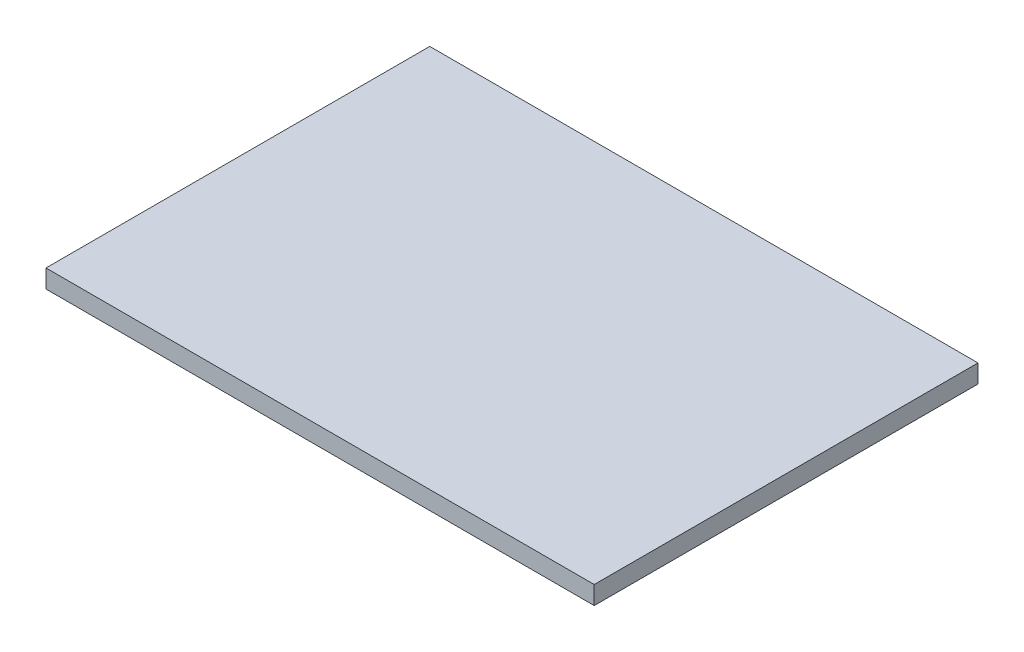
from build123d import *

# Parameters (mm, degrees)
SKETCH1_W           = 30
SKETCH1_H           = 21
BOSS_EXTRUDE1_DEPTH = 1


with BuildPart() as part:
    # Sketch1 → Boss-Extrude1 (new body)
    with BuildSketch(Plane(origin=(0, 0, 0), x_dir=(1, 0, 0), z_dir=(0, 1, 0))):
        with Locations((1.7, 2.1)):
            Rectangle(SKETCH1_W, SKETCH1_H)
    extrude(amount=BOSS_EXTRUDE1_DEPTH)


solid = part.part
